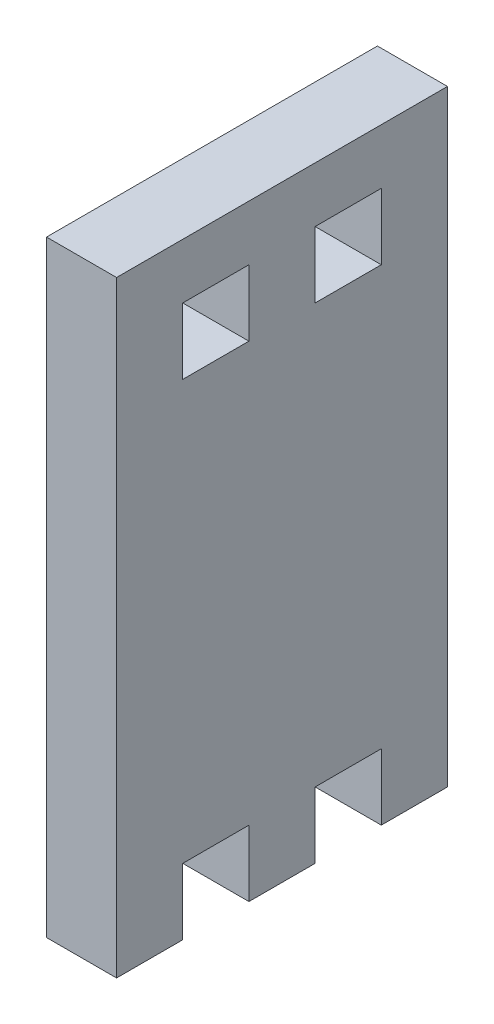
from build123d import *

# Parameters (mm, degrees)
SKETCH1_W           = 6
SKETCH1_H           = 6
BOSS_EXTRUDE1_DEPTH = 6.35


with BuildPart() as part:
    # Sketch1 → Boss-Extrude1 (new body)
    with BuildSketch(Plane(origin=(0, 0, 0), x_dir=(0, 0, -1), z_dir=(1, 0, 0))):
        Polygon((-3, -21.5), (-3, -27.5), (3, -27.5), (3, -21.5), (9, -21.5), (9, -27.5), (15, -27.5), (15, 27.5), (-15, 27.5), (-15, -27.5), (-9, -27.5), (-9, -21.5), align=None)
        with Locations((6, 19.5)):
            Rectangle(SKETCH1_W, SKETCH1_H, mode=Mode.SUBTRACT)
        with Locations((-6, 19.5)):
            Rectangle(SKETCH1_W, SKETCH1_H, mode=Mode.SUBTRACT)
    extrude(amount=BOSS_EXTRUDE1_DEPTH)


solid = part.part
